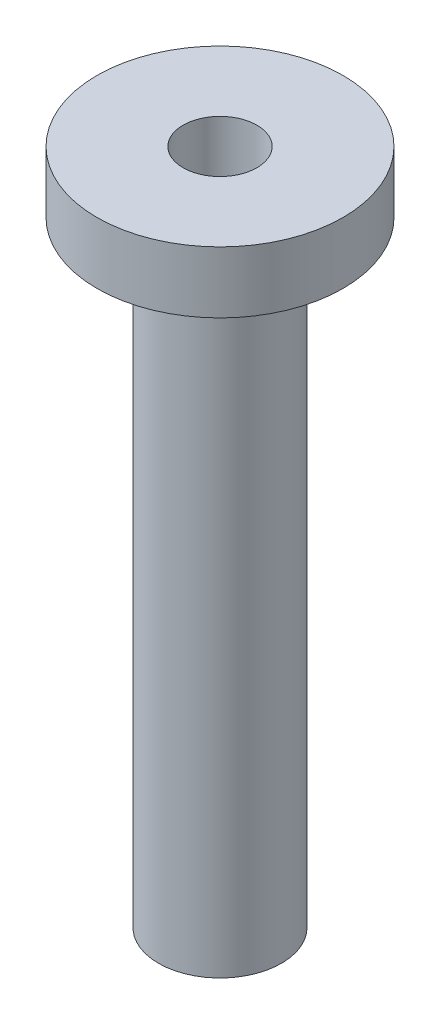
from build123d import *


with BuildPart() as part:
    # Sketch1 → Revolve1 (revolve)
    with BuildSketch(Plane.XY):
        Polygon((-3.81, 0), (-12.7, 0), (-12.7, -6.35), (-11.1125, -6.35), (-11.1125, -4.318), (-8.0645, -4.318), (-8.0645, -6.35), (-6.35, -6.35), (-6.35, -69.85), (-3.81, -67.31), align=None)
    revolve(axis=Axis((0, 0, 0), (0, -1, 0)))


solid = part.part
